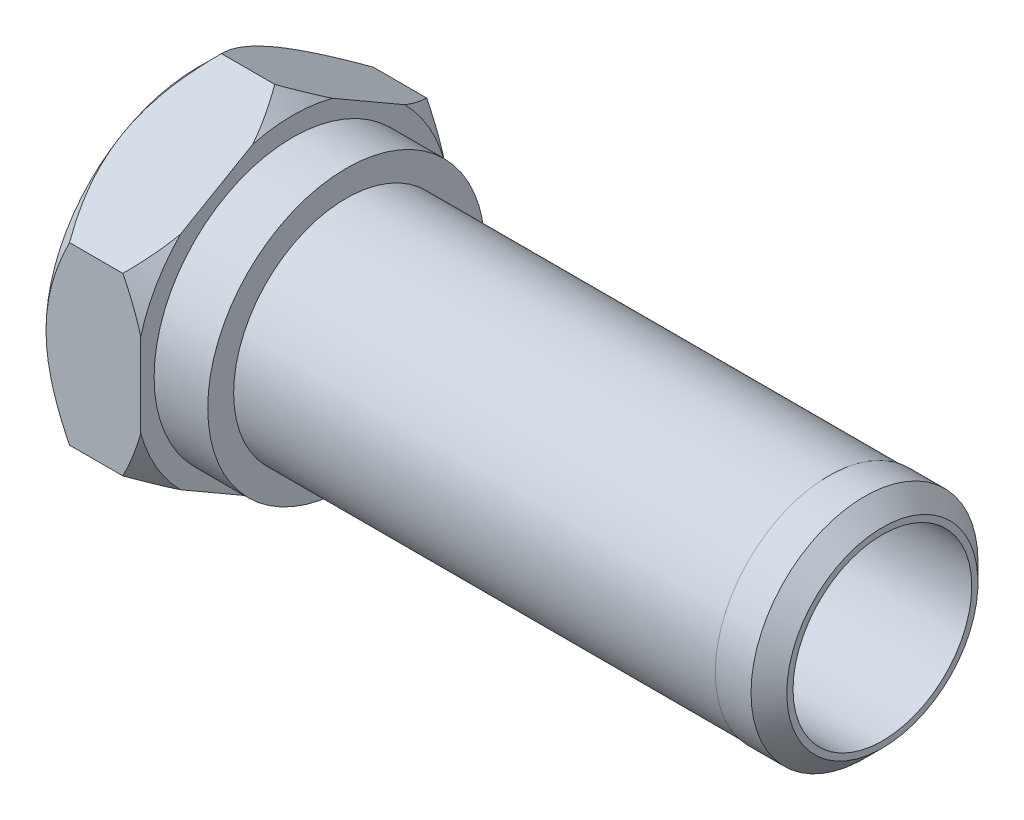
from build123d import *

# Parameters (mm, degrees)
SFAZOWANIE2_SIZE            = 1
SZKIC2_W                    = 27
SZKIC2_H                    = 0.05
SZKIC3_R                    = 5
DODANIE_WYCI_GNI_CIE1_DEPTH = 5.3
SFAZOWANIE3_SIZE            = 0.5


with BuildPart() as part:
    # Szkic1 → Obrót1 (revolve)
    with BuildSketch(Plane.XY, mode=Mode.PRIVATE) as obr_t1_sk:
        Polygon((0, 5), (33, 5), (33, 6.35), (3, 6.35), (3, 7.75), (0, 7.75), align=None)
    revolve(obr_t1_sk.sketch.rotate(Axis((0, 0, 0), (1, 0, 0)), 90), axis=Axis((0, 0, 0), (1, 0, 0)))

    # Sfazowanie2
    sfazowanie2_edges = [part.edges().sort_by_distance(p)[0] for p in [
        (33, 0, -6.35),
    ]]
    chamfer(sfazowanie2_edges, length=SFAZOWANIE2_SIZE)

    # Szkic2 → Wycięcie-obrót1 (revolve, cut)
    with BuildSketch(Plane.XY, mode=Mode.PRIVATE) as wyci_cie_obr_t1_sk:
        with Locations((16.5, 6.325)):
            Rectangle(SZKIC2_W, SZKIC2_H)
    revolve(wyci_cie_obr_t1_sk.sketch.rotate(Axis((3, 0, 0), (1, 0, 0)), 90), axis=Axis((3, 0, 0), (1, 0, 0)), mode=Mode.SUBTRACT)

    # Szkic3 → Dodanie-wyciągnięcie1 (add)
    with BuildSketch(Plane.ZY):
        Polygon((8.5, -4.907477288), (8.5, 4.907477288), (0, 9.814954576), (-8.5, 4.907477288), (-8.5, -4.907477288), (0, -9.814954576), align=None)
        Circle(SZKIC3_R, mode=Mode.SUBTRACT)
    extrude(amount=DODANIE_WYCI_GNI_CIE1_DEPTH)

    # Szkic4 → Wycięcie-obrót2 (revolve, cut)
    with BuildSketch(Plane(origin=(0, 0, 0), x_dir=(1, 0, 0), z_dir=(0, 1, 0)), mode=Mode.PRIVATE) as wyci_cie_obr_t2_sk:
        Polygon((-5.3, 8.5), (-5.3, 12), (-1.8, 12), align=None)
    revolve(wyci_cie_obr_t2_sk.sketch.rotate(Axis((0, 0, 0), (-1, 0, 0)), 180), axis=Axis((0, 0, 0), (-1, 0, 0)), mode=Mode.SUBTRACT)

    # Szkic5 → Wycięcie-obrót3 (revolve, cut)
    with BuildSketch(Plane.XY, mode=Mode.PRIVATE) as wyci_cie_obr_t3_sk:
        Polygon((0, -8.814954576), (0, -9.814954576), (-1, -9.814954576), align=None)
    revolve(wyci_cie_obr_t3_sk.sketch.rotate(Axis((0, 0, 0), (1, 0, 0)), 270), axis=Axis((0, 0, 0), (1, 0, 0)), mode=Mode.SUBTRACT)

    # Sfazowanie3
    sfazowanie3_edges = [part.edges().sort_by_distance(p)[0] for p in [
        (-5.3, 0, -5),
    ]]
    chamfer(sfazowanie3_edges, length=SFAZOWANIE3_SIZE)


solid = part.part
